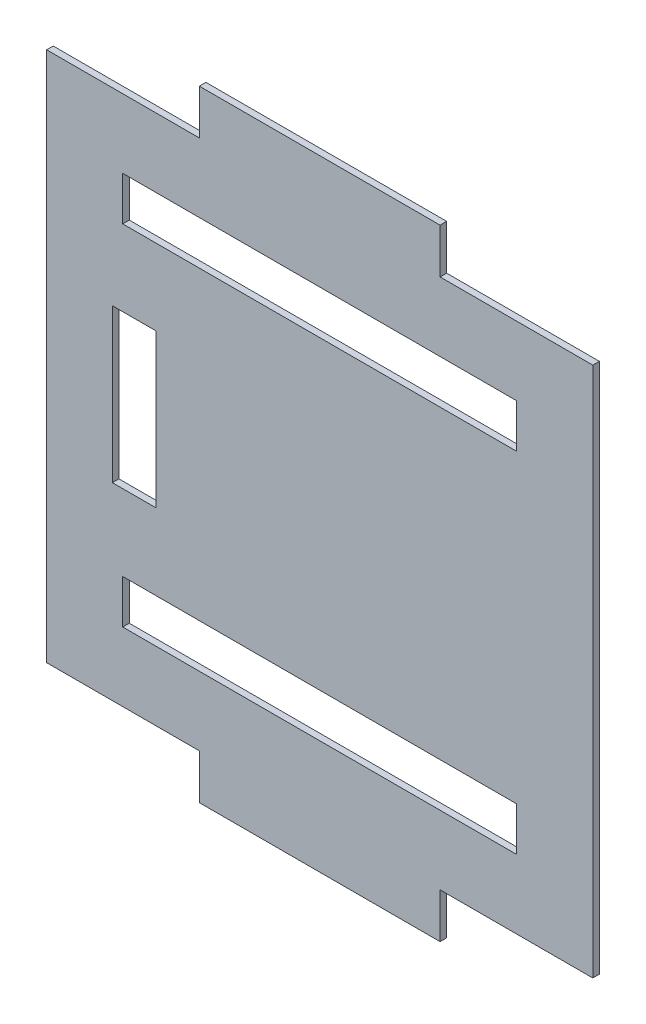
from build123d import *

# Parameters (mm, degrees)
BASE_DEPTH              = 3
PROFIL_S_DEPTH          = 3
ESQUISSE3_W             = 180
ESQUISSE3_H             = 20
ESQUISSE3_W_2           = 20
ESQUISSE3_H_2           = 70
ENL_V_MAT_EXTRU_1_DEPTH = 3


with BuildPart() as part:
    # Esquisse1 → Base (new body)
    with BuildSketch(Plane.XY):
        Polygon((0, 0), (-200, 0), (-224.748737342, 24.748737342), (-224.748737342, 284.748737342), (-200, 309.497474683), (0, 309.497474683), (24.748737342, 284.748737342), (24.748737342, 24.748737342), align=None)
    extrude(amount=BASE_DEPTH)

    # Esquisse2 → profilés (cut)
    with BuildSketch(Plane.XY.offset(3)):
        Polygon((-45, 13), (-155, 13), (-155, 33.5), (-224.748737342, 33.5), (-224.748737342, 0), (24.748737342, 0), (24.748737342, 33.5), (-45, 33.5), align=None)
        Polygon((24.748737342, 309.497474683), (24.748737342, 275.997474683), (-45, 275.997474683), (-45, 296.497474683), (-155, 296.497474683), (-155, 275.997474683), (-224.748737342, 275.997474683), (-224.748737342, 309.497474683), align=None)
    extrude(amount=-PROFIL_S_DEPTH, mode=Mode.SUBTRACT)

    # Esquisse3 → Enlèv. mat.-Extru.1 (cut)
    with BuildSketch(Plane.XY.offset(3)):
        with Locations((-100, 234.497474683)):
            Rectangle(ESQUISSE3_W, ESQUISSE3_H)
        with Locations((-100, 75)):
            Rectangle(ESQUISSE3_W, ESQUISSE3_H)
        with Locations((-184.748737342, 154.748737342)):
            Rectangle(ESQUISSE3_W_2, ESQUISSE3_H_2)
    extrude(amount=-ENL_V_MAT_EXTRU_1_DEPTH, mode=Mode.SUBTRACT)


solid = part.part
